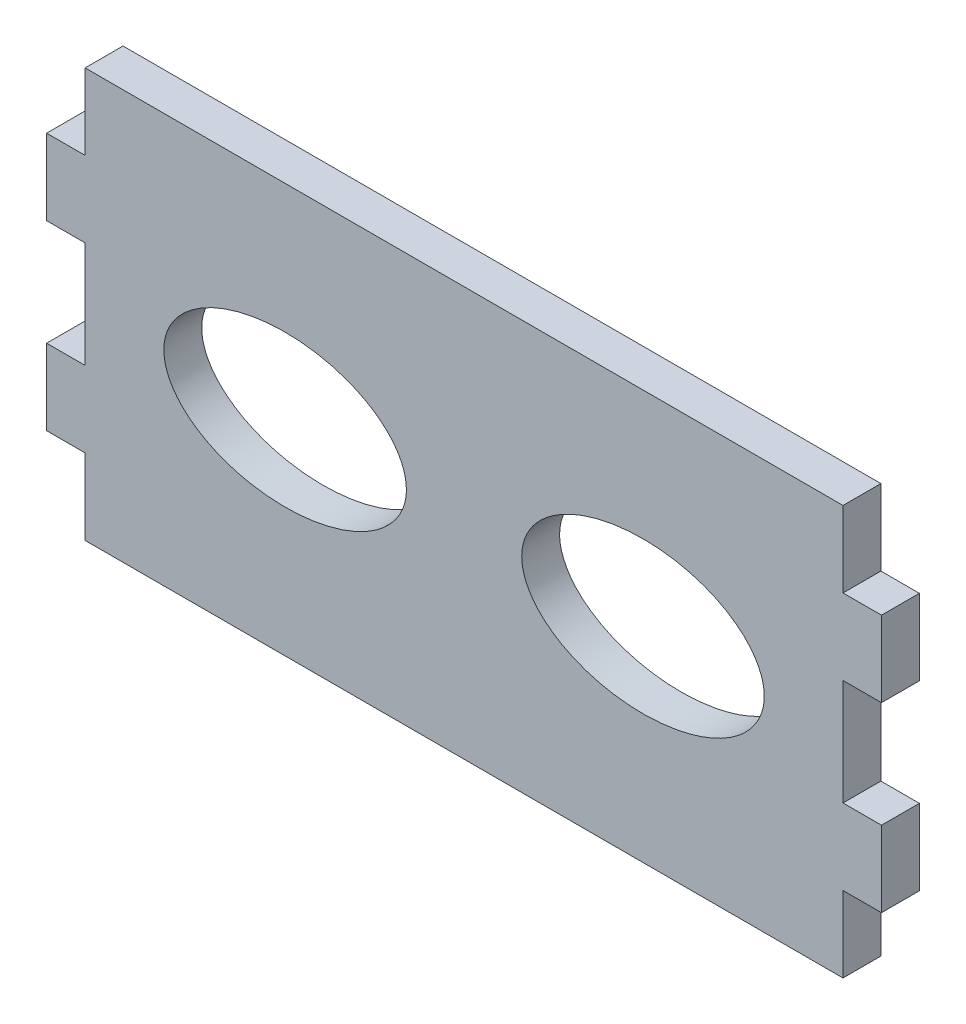
from build123d import *

# Parameters (mm, degrees)
SKETCH1_W                      = 63.5
SKETCH1_H                      = 34.29
BOSS_EXTRUDE1_DEPTH            = 3.175
SKETCH2_W                      = 3.2258
SKETCH2_H                      = 6.35
BOSS_EXTRUDE2_DEPTH            = 3.175
SKETCH3_RX                     = 10.16
SKETCH3_RY                     = 6.35
CUT_FOR_LIP_MOTOR_CABLES_DEPTH = 4.175


with BuildPart() as part:
    # Sketch1 → Boss-Extrude1 (new body)
    with BuildSketch(Plane.XY):
        Rectangle(SKETCH1_W, SKETCH1_H)
    extrude(amount=BOSS_EXTRUDE1_DEPTH)

    # Sketch2 → Boss-Extrude2 (add)
    with BuildSketch(Plane.XY.offset(3.175)):
        with Locations((-33.3629, 7.62)):
            Rectangle(SKETCH2_W, SKETCH2_H)
        with Locations((-33.3629, -7.62)):
            Rectangle(SKETCH2_W, SKETCH2_H)
    boss_extrude2 = extrude(amount=-BOSS_EXTRUDE2_DEPTH)

    # Mirror1: Boss-Extrude2 across plane
    add(boss_extrude2.mirror(Plane(origin=(0, 0, 0), x_dir=(0, 0, 1), z_dir=(1, 0, 0))))

    # Sketch3 → cut for lip motor cables (cut, through all)
    with BuildSketch(Plane(origin=(0, 0, 0), x_dir=(-1, 0, 0), z_dir=(0, 0, -1))):
        with Locations(Location((-14.992180724, 0), (0, 0, 180))):
            Ellipse(SKETCH3_RX, SKETCH3_RY)
    cut_for_lip_motor_cables = extrude(amount=-CUT_FOR_LIP_MOTOR_CABLES_DEPTH, mode=Mode.SUBTRACT)

    # Mirror2: cut for lip motor cables across plane
    add(cut_for_lip_motor_cables.mirror(Plane(origin=(0, 0, 0), x_dir=(0, 0, 1), z_dir=(1, 0, 0))), mode=Mode.SUBTRACT)


solid = part.part
